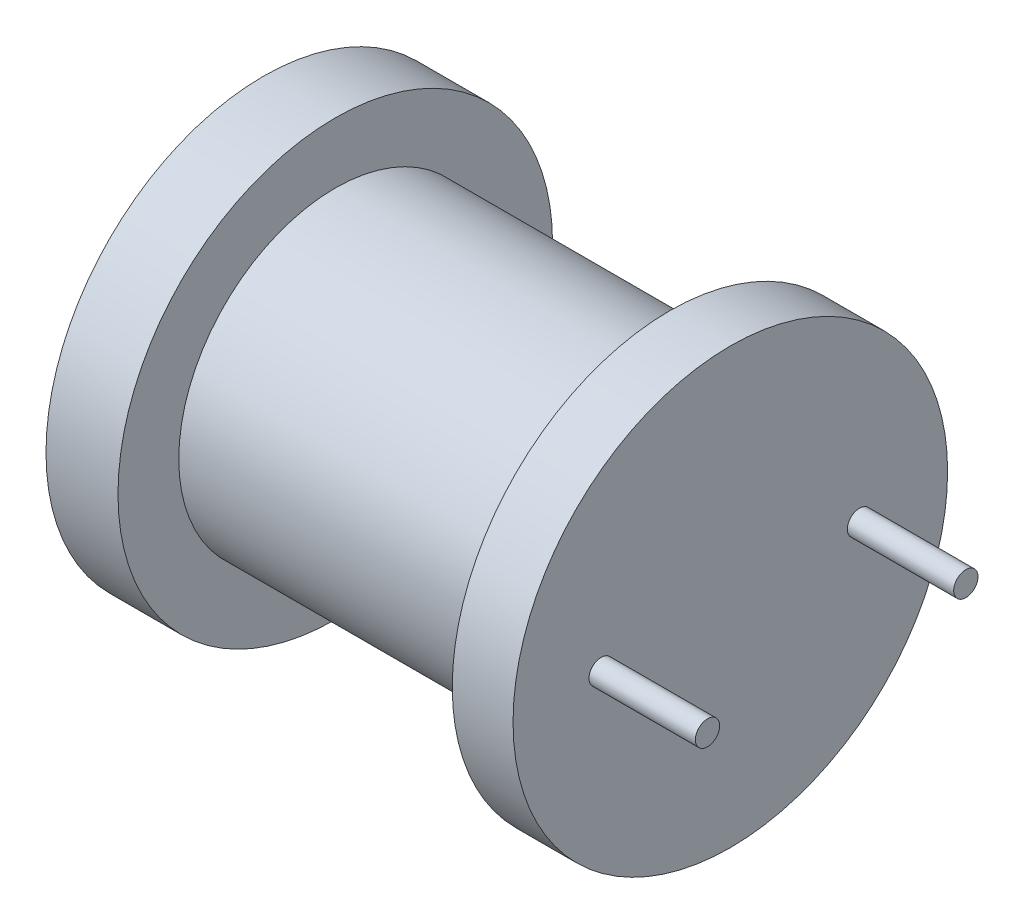
from build123d import *

# Parameters (mm, degrees)
SKETCH_2_R      = 0.4
EXTRUDE_1_DEPTH = 3.5


with BuildPart() as part:
    # Эскиз1 → Повернуть1 (revolve)
    with BuildSketch(Plane.XY):
        Polygon((0, 0), (0, 7), (0.031301632, 7.15), (2.4, 7.15), (2.4, 5.15), (13.4, 5.15), (13.4, 7.15), (15.4, 7.15), (15.4, 0), align=None)
    revolve(axis=Axis((-29.538793103, 0, 0), (1, 0, 0)))

    # Эскиз2 → Бобышка-Вытянуть1 (add)
    with BuildSketch(Plane(origin=(15.4, 0, 0), x_dir=(0, 0, -1), z_dir=(1, 0, 0))):
        with Locations((-4.25, 0)):
            Circle(SKETCH_2_R)
        with Locations((4.25, 0)):
            Circle(SKETCH_2_R)
    extrude(amount=EXTRUDE_1_DEPTH)


solid = part.part
